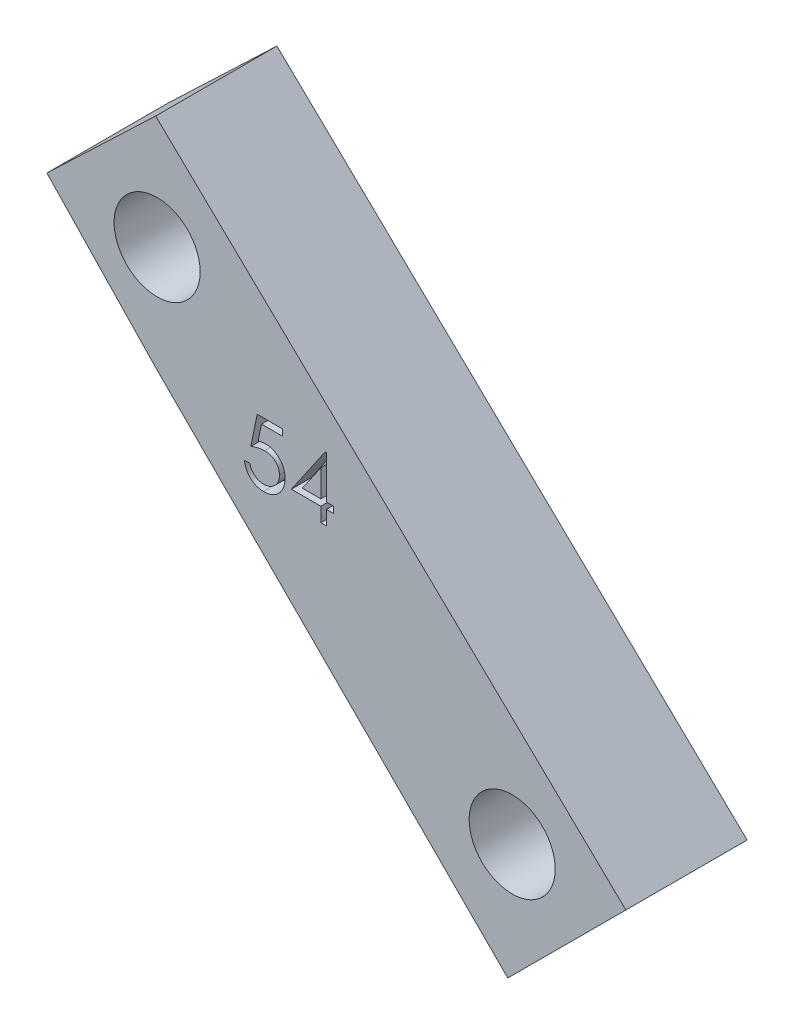
from build123d import *

# Parameters (mm, degrees)
SKETCH1_R           = 2.2
BOSS_EXTRUDE1_DEPTH = 6.2
CUT_EXTRUDE1_DEPTH  = 1


with BuildPart() as part:
    # Sketch1 → Boss-Extrude1 (new body)
    with BuildSketch(Plane(origin=(0, 0, 0), x_dir=(-1, 0, 0), z_dir=(0, 0, 1))):
        Polygon((-144.298520867, 82.267611076), (-149.806405315, 88.04360735), (-167.861763168, 106.127941253), (-173.899609442, 100.09976926), (-149.860209976, 76.964086023), align=None)
        with Locations((-149.935011138, 82.733649845)):
            Circle(SKETCH1_R, mode=Mode.SUBTRACT)
        with Locations((-168.087755201, 100.095717423)):
            Circle(SKETCH1_R, mode=Mode.SUBTRACT)
    extrude(amount=BOSS_EXTRUDE1_DEPTH)

    # Sketch2 → Cut-Extrude1 (cut)
    with BuildSketch(Plane.XY.offset(6.2)):
        with BuildLine():
            Line((156.351932178, -87.573874819), (156.351932178, -87.899515844))
            Line((156.351932178, -87.899515844), (155.271974245, -87.899515844))
            Line((155.271974245, -87.899515844), (155.100885503, -88.73460699))
            add(Edge.make_bspline(
                [(155.100885503, -88.73460699), (155.134500475, -88.725326672), (155.199624166, -88.707347524), (155.295744897, -88.687385146), (155.386996396, -88.675351494), (155.446210482, -88.673708376), (155.474863868, -88.67291328)],
                knots=[0, 0, 0, 0, 0.000104595, 0.000202637, 0.000294305, 0.000380252, 0.000380252, 0.000380252, 0.000380252], degree=3))
            add(Edge.make_bspline(
                [(155.474863868, -88.67291328), (155.510318404, -88.673680665), (155.580030878, -88.675189535), (155.682029066, -88.689678284), (155.779395334, -88.712483778), (155.871926055, -88.744343108), (155.959792412, -88.785082652), (156.042185985, -88.835973312), (156.120343521, -88.895421405), (156.192862874, -88.963770095), (156.258652782, -89.038991847), (156.316497644, -89.119870773), (156.365630851, -89.205620866), (156.405146679, -89.297061419), (156.436701039, -89.393181508), (156.457703206, -89.494992493), (156.471688363, -89.601534717), (156.473250814, -89.674382434), (156.474047562, -89.711530067)],
                knots=[0, 0, 0, 0, 0.000106308, 0.000209029, 0.000308378, 0.000405929, 0.000502102, 0.000598312, 0.00069588, 0.000796219, 0.000896736, 0.000995218, 0.001094066, 0.001192613, 0.001293582, 0.001396995, 0.001504047, 0.001615439, 0.001615439, 0.001615439, 0.001615439], degree=3))
            add(Edge.make_bspline(
                [(156.474047562, -89.711530067), (156.473444244, -89.737403796), (156.472245761, -89.788801592), (156.466151042, -89.865132402), (156.4544165, -89.939847258), (156.438661493, -90.012956071), (156.418212299, -90.08432043), (156.393457229, -90.154144601), (156.363162261, -90.221993995), (156.329932371, -90.288510603), (156.292515923, -90.352190677), (156.250988277, -90.411743687), (156.207113867, -90.468062999), (156.159904896, -90.5205446), (156.108922565, -90.568843623), (156.054784309, -90.613246707), (155.997922128, -90.654504771), (155.937456301, -90.690943062), (155.874734192, -90.724473744), (155.808850023, -90.751981524), (155.741303531, -90.776574646), (155.671122536, -90.796177575), (155.598466006, -90.811537821), (155.523214174, -90.821970508), (155.445761709, -90.829569134), (155.393260805, -90.8300448), (155.366740872, -90.830285075)],
                knots=[0, 0, 0, 0, 7.7636e-05, 0.000154223, 0.000229512, 0.000304362, 0.000378447, 0.000452077, 0.000526407, 0.000601214, 0.00067506, 0.000747747, 0.00081887, 0.000889121, 0.000959302, 0.001029336, 0.001099058, 0.00116985, 0.001240974, 0.00131221, 0.00138383, 0.001456517, 0.001530612, 0.001606437, 0.001684346, 0.001763871, 0.001763871, 0.001763871, 0.001763871], degree=3))
            add(Edge.make_bspline(
                [(155.366740872, -90.830285075), (155.335105008, -90.829658386), (155.272865183, -90.82842545), (155.181678668, -90.815527253), (155.093944705, -90.797054272), (155.010369541, -90.769262798), (154.930204181, -90.734440038), (154.854527858, -90.69042894), (154.781406904, -90.640555039), (154.713813842, -90.58169929), (154.651079368, -90.517368635), (154.594921321, -90.447557061), (154.54490729, -90.373416781), (154.501838191, -90.294587742), (154.4651007, -90.211277074), (154.436239961, -90.123172638), (154.412946025, -90.030734777), (154.403091351, -89.967095521), (154.398086024, -89.934772255)],
                knots=[0, 0, 0, 0, 9.4843e-05, 0.000186593, 0.000275792, 0.000363484, 0.000450342, 0.000537514, 0.000625728, 0.000715478, 0.000805885, 0.000894984, 0.00098389, 0.001073836, 0.001164117, 0.001256635, 0.001351658, 0.001449737, 0.001449737, 0.001449737, 0.001449737], degree=3))
            Line((154.398086024, -89.934772255), (154.683021921, -89.934772255))
            add(Edge.make_bspline(
                [(154.683021921, -89.934772255), (154.690032827, -89.965049465), (154.703508177, -90.023243945), (154.733086249, -90.105005947), (154.769250293, -90.177866957), (154.812252809, -90.242790794), (154.863551765, -90.29940467), (154.922089176, -90.34985729), (154.987718896, -90.3953733), (155.06064704, -90.433312525), (155.137584619, -90.46566918), (155.21810916, -90.48721536), (155.300028103, -90.502365456), (155.35543491, -90.503881982), (155.38327733, -90.50464405)],
                knots=[0, 0, 0, 0, 9.3172e-05, 0.000179081, 0.000260145, 0.000336703, 0.000411917, 0.000488562, 0.000568128, 0.000650923, 0.00073478, 0.000817953, 0.000900557, 0.000983994, 0.000983994, 0.000983994, 0.000983994], degree=3))
            add(Edge.make_bspline(
                [(155.38327733, -90.50464405), (155.410453919, -90.503899487), (155.463964845, -90.502433437), (155.542715174, -90.491149476), (155.618745424, -90.473770822), (155.691305384, -90.447763167), (155.76166478, -90.41615403), (155.828043843, -90.375591068), (155.892362882, -90.32890948), (155.952622689, -90.275427394), (156.007812761, -90.2164906), (156.056577242, -90.153464679), (156.097196299, -90.086230111), (156.131426526, -90.015950894), (156.157419162, -89.941856774), (156.175962052, -89.864294994), (156.186850541, -89.783073976), (156.188348397, -89.727675388), (156.189111665, -89.699445732)],
                knots=[0, 0, 0, 0, 8.15e-05, 0.000160473, 0.000238226, 0.000315066, 0.000391338, 0.000469218, 0.000547964, 0.000629516, 0.000710512, 0.000789892, 0.000868102, 0.000945761, 0.001024012, 0.00110315, 0.001184644, 0.001269321, 0.001269321, 0.001269321, 0.001269321], degree=3))
            add(Edge.make_bspline(
                [(156.189111665, -89.699445732), (156.18851433, -89.673977015), (156.187345132, -89.624125624), (156.1777924, -89.551192058), (156.16117629, -89.482182941), (156.138113198, -89.416765029), (156.108831074, -89.354876621), (156.073047633, -89.296453844), (156.030091336, -89.242266724), (155.981022266, -89.192289908), (155.927266758, -89.146166343), (155.867899934, -89.106847064), (155.804164143, -89.073769082), (155.736827292, -89.045223112), (155.664287706, -89.024721007), (155.587981903, -89.009328711), (155.50708589, -89.000424775), (155.451776766, -88.999189348), (155.423346441, -88.998554306)],
                knots=[0, 0, 0, 0, 7.6388e-05, 0.000149519, 0.000220172, 0.000288967, 0.000357247, 0.000425206, 0.000494043, 0.000564207, 0.000635056, 0.000706145, 0.000777268, 0.000850264, 0.000925136, 0.001002969, 0.001083601, 0.001168886, 0.001168886, 0.001168886, 0.001168886], degree=3))
            add(Edge.make_bspline(
                [(155.423346441, -88.998554306), (155.398736627, -88.999080985), (155.347923604, -89.000168444), (155.269979326, -89.008175337), (155.188071834, -89.021092412), (155.102515113, -89.038859936), (155.013052224, -89.062110984), (154.91987196, -89.089973424), (154.822778404, -89.123285523), (154.757357326, -89.148442603), (154.72372705, -89.161374819)],
                knots=[0, 0, 0, 0, 7.3822e-05, 0.000152423, 0.000234822, 0.000322511, 0.00041445, 0.000512043, 0.000614219, 0.000722306, 0.000722306, 0.000722306, 0.000722306], degree=3))
            Line((154.72372705, -89.161374819), (155.049368075, -87.573874819))
            Line((155.049368075, -87.573874819), (156.351932178, -87.573874819))
        make_face()
        Polygon((158.532836625, -87.492464562), (158.590714229, -87.492464562), (158.590714229, -89.690541485), (158.957060383, -89.690541485), (158.957060383, -90.016182511), (158.590714229, -90.016182511), (158.590714229, -90.748874819), (158.305778332, -90.748874819), (158.305778332, -90.016182511), (156.799688588, -90.016182511), align=None)
        Polygon((158.305778332, -89.690541485), (158.305778332, -88.311655268), (157.359384101, -89.690541485), align=None, mode=Mode.SUBTRACT)
    extrude(amount=-CUT_EXTRUDE1_DEPTH, mode=Mode.SUBTRACT)


solid = part.part
